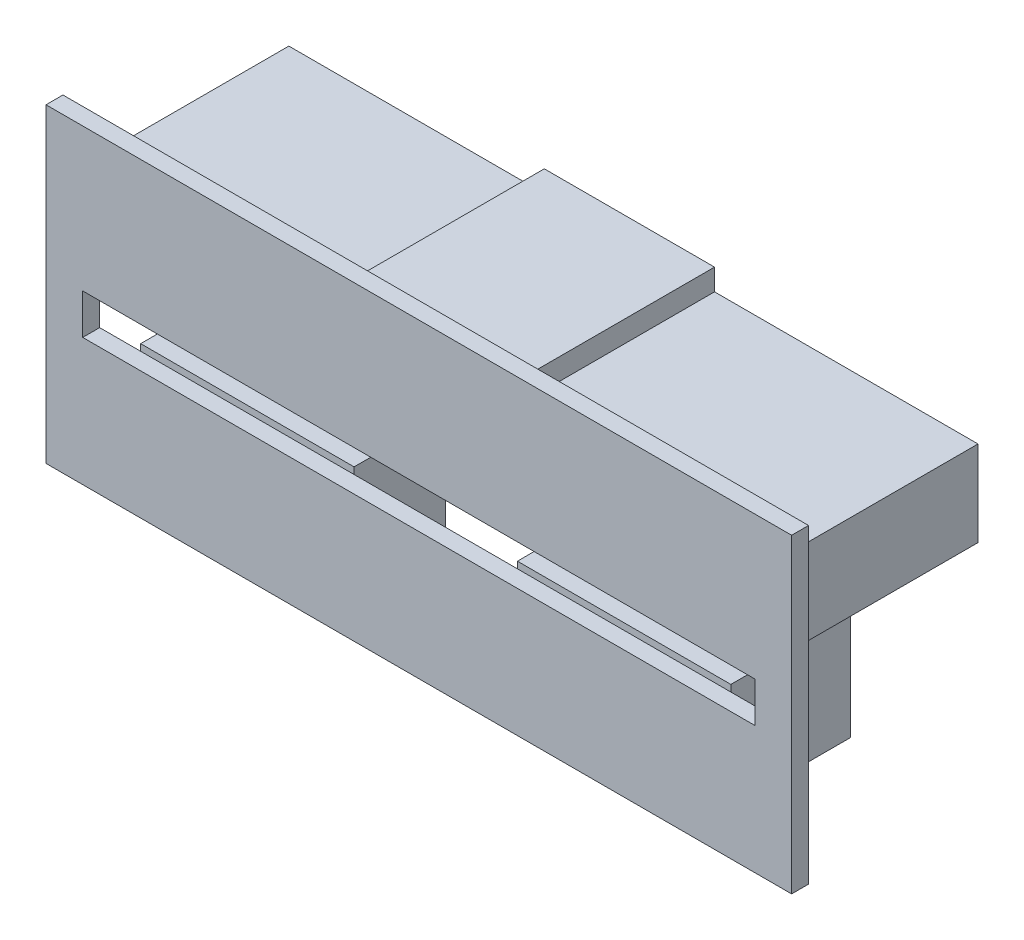
from build123d import *

# Parameters (mm, degrees)
SALIENTE_EXTRUIR1_DEPTH   = 7.5
SALIENTE_EXTRUIR1_2_DEPTH = 7.5
SALIENTE_EXTRUIR2_DEPTH   = 14
CROQUIS4_W                = 52.808095268
CROQUIS4_H                = 22
CROQUIS4_W_2              = 47.625032345
CROQUIS4_H_2              = 2.85152228
SALIENTE_EXTRUIR3_DEPTH   = 1.2


with BuildPart() as part:
    # Croquis2 → Saliente-Extruir1 (new body)
    with BuildSketch(Plane(origin=(0, -12.4, 0), x_dir=(1, 0, 0), z_dir=(0, 1, 0))):
        with BuildLine():
            Line((20.9, 0), (20.9, 8.468551509))
            ThreePointArc((20.9, 8.468551509), (14.039862076, 2.13695997), (5.744958612, 6.420080362))
            Line((5.744958612, 6.420080362), (5.788277469, 0))
            Line((5.788277469, 0), (20.9, 0))
        make_face()
    extrude(amount=SALIENTE_EXTRUIR1_DEPTH)



with BuildPart() as body_2:
    # Croquis2 → Saliente-Extruir1 2 (new body)
    with BuildSketch(Plane(origin=(0, -12.4, 0), x_dir=(1, 0, 0), z_dir=(0, 1, 0))):
        with BuildLine():
            ThreePointArc((-20.9, 8.468551509), (-14.039862076, 2.13695997), (-5.744958612, 6.420080362))
            Line((-5.744958612, 6.420080362), (-5.788277469, 0))
            Line((-5.788277469, 0), (-20.9, 0))
            Line((-20.9, 0), (-20.9, 8.468551509))
        make_face()
    extrude(amount=SALIENTE_EXTRUIR1_2_DEPTH)


with BuildPart() as body_3:
    # Croquis3 → Saliente-Extruir2 (new body)
    with BuildSketch(Plane.XY):
        Polygon((24.404047634, 4.6), (24.404047634, 1.902402318), (24.404047634, -1.452453504), (22.804047634, -1.452453504), (22.804047634, 1.902402318), (-22.804047634, 1.902402318), (-22.804047634, -1.452453504), (-24.404047634, -1.452453504), (-24.404047634, 1.902402318), (-24.404047634, 4.6), (-6.312940469, 4.6), (-6.312940469, 6.117496706), (5.744958612, 6.117496706), (5.744958612, 4.6), align=None)
    extrude(amount=-SALIENTE_EXTRUIR2_DEPTH)


with BuildPart() as part_1:
    add(part.part)

    add(body_2.part)  # Saliente-Extruir3 merges body 2

    add(body_3.part)  # Saliente-Extruir3 merges body 3
    # Croquis4 → Saliente-Extruir3 (add)
    with BuildSketch(Plane.XY):
        with Locations((0, -3.4)):
            Rectangle(CROQUIS4_W, CROQUIS4_H)
        with Locations((0.009244494, -3.943262508)):
            Rectangle(CROQUIS4_W_2, CROQUIS4_H_2, mode=Mode.SUBTRACT)
    extrude(amount=SALIENTE_EXTRUIR3_DEPTH)


solid = part_1.part
